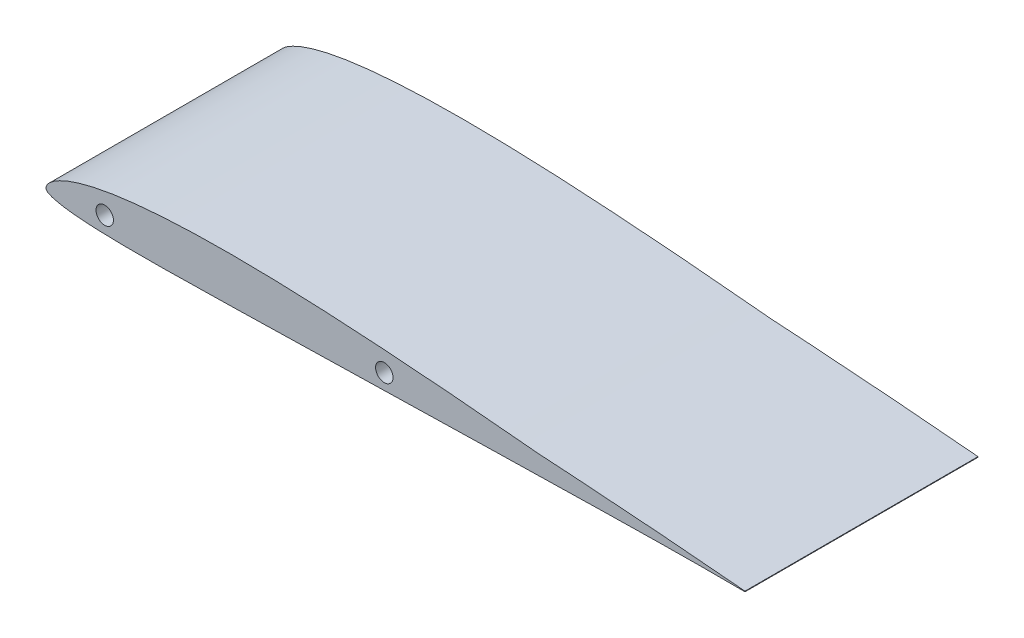
from build123d import *

# Parameters (mm, degrees)
BOSS_EXTRUDE1_DEPTH = 12.7
SKETCH3_R           = 0.9525
CUT_EXTRUDE1_DEPTH  = 26.4000001


with BuildPart() as part:
    # Sketch2 → Boss-Extrude1 (new body, symmetric)
    with BuildSketch(Plane.XY):
        with BuildLine():
            Line((64.718169848, -2.499143417), (64.718169848, -2.563456217))
            add(Edge.make_bspline(
                [(64.718169848, -2.499143417), (64.57008636, -2.485647197), (64.120909862, -2.444709582), (63.33092074, -2.371899023), (62.340988393, -2.285370828), (61.302858292, -2.194006348), (60.255749726, -2.102061217), (59.20564087, -2.013761116), (58.154298765, -1.925517783), (57.102103695, -1.839326159), (56.049602468, -1.754055917), (54.997055842, -1.670644215), (53.944788878, -1.589446986), (52.892846219, -1.508577494), (51.841324845, -1.430244971), (50.790005293, -1.352784355), (49.739245225, -1.276796753), (48.688636524, -1.202920087), (47.638508452, -1.129434553), (46.588535299, -1.057980828), (45.538973846, -0.987918085), (44.489525544, -0.919015022), (43.518569776, -0.856341226), (42.76371797, -0.809534693), (42.292113415, -0.778415282), (42.025102923, -0.764814001), (41.759900322, -0.736388122), (41.202070401, -0.684614179), (40.352064753, -0.602008925), (39.458214557, -0.518614415), (38.659237572, -0.444523122), (37.943339835, -0.378547436), (37.046267968, -0.297124129), (35.998306453, -0.203164046), (34.928593526, -0.109310266), (33.861679664, -0.017438796), (32.855925072, 0.067572446), (31.866593503, 0.149614421), (31.004614735, 0.219417223), (30.293193682, 0.276018624), (29.510637716, 0.337620449), (28.603924699, 0.406949286), (27.54916619, 0.48546654), (26.495103884, 0.561602222), (25.090353833, 0.659252903), (23.685759277, 0.751291385), (22.281448375, 0.837223705), (21.228463131, 0.898255328), (19.824860498, 0.975033121), (18.421400918, 1.044436007), (17.018020949, 1.105700039), (15.965855347, 1.147620542), (14.913927824, 1.184599621), (13.86231012, 1.216897884), (12.811147492, 1.244135927), (11.760493176, 1.266133962), (10.710364611, 1.282102535), (9.660770547, 1.292262127), (8.611804321, 1.295567333), (7.563748545, 1.2918548), (6.516728957, 1.280563888), (5.470993065, 1.261320698), (4.426697539, 1.233075932), (3.384243741, 1.195262013), (2.344154999, 1.147118546), (1.30677499, 1.087405461), (0.272951002, 1.01553077), (-0.756620414, 0.929630454), (-1.780995367, 0.828802249), (-2.798496801, 0.71071689), (-3.807643769, 0.574000519), (-4.805483481, 0.415836094), (-5.789196027, 0.233022375), (-6.753228823, 0.021955146), (-7.688827407, -0.221784244), (-8.578803858, -0.500074337), (-9.390128632, -0.81024109), (-10.075256249, -1.135525802), (-10.597529728, -1.448279294), (-10.957831672, -1.722355697), (-11.191738015, -1.949535299), (-11.340509909, -2.137925591), (-11.430618932, -2.298135772), (-11.476263277, -2.435744728), (-11.486757749, -2.556943481), (-11.460570081, -2.67120322), (-11.385368171, -2.78094718), (-11.252723362, -2.878628732), (-11.060363948, -2.977989982), (-10.777566168, -3.085187835), (-10.357827972, -3.204452959), (-9.76381891, -3.326330683), (-9.001331339, -3.439940748), (-8.116566771, -3.534084158), (-7.163694507, -3.606537927), (-6.176610039, -3.660215446), (-5.170969518, -3.698306831), (-4.153573582, -3.724180705), (-3.127995371, -3.740661828), (-2.096446559, -3.749635345), (-1.060235457, -3.752445761), (-0.020474584, -3.749525578), (1.022277045, -3.741896418), (2.067312992, -3.730492352), (3.114426337, -3.715621838), (4.163393847, -3.698251135), (5.214518698, -3.678787057), (6.267806047, -3.657863163), (7.323370126, -3.635311381), (8.381208951, -3.612442836), (9.441526554, -3.58839108), (10.504158632, -3.563905056), (11.92468281, -3.530891983), (13.347254295, -3.497196209), (14.771533214, -3.463588408), (15.841306634, -3.438409492), (16.911989828, -3.413034467), (17.983720411, -3.387888031), (19.056638023, -3.362504757), (20.130171202, -3.337425871), (21.203624946, -3.312336311), (22.276341611, -3.287377164), (23.348379195, -3.262811402), (24.419769067, -3.237871165), (25.490460003, -3.213616847), (26.560356365, -3.189302594), (27.629547828, -3.165394729), (28.698274525, -3.141302604), (29.602999191, -3.121201632), (30.657839619, -3.097853241), (31.698496831, -3.074385325), (32.881556151, -3.048178049), (33.911248665, -3.025327622), (34.944439624, -3.002098161), (35.988356279, -2.978974483), (36.922745567, -2.958275767), (37.740802843, -2.940242749), (38.431888121, -2.925199346), (39.226828943, -2.907764909), (40.139859265, -2.888092993), (40.983543149, -2.869810874), (41.55545359, -2.857761964), (41.832816963, -2.851718705), (42.068512365, -2.847220389), (42.546962239, -2.836679811), (43.325221031, -2.820460579), (44.348128788, -2.799096504), (45.404564547, -2.777351387), (46.460445741, -2.756095746), (47.516040759, -2.734807335), (48.571770091, -2.714116178), (49.627668411, -2.693328458), (50.683826195, -2.673277267), (51.740126636, -2.653577236), (52.796721419, -2.635838614), (54.205844553, -2.613436359), (55.615446657, -2.59433613), (57.025184273, -2.578294433), (58.082920356, -2.568677707), (59.140702632, -2.560641626), (60.198743058, -2.555318446), (61.256274736, -2.552644269), (62.307053135, -2.552213775), (63.310478787, -2.556353053), (64.112102133, -2.560000457), (64.56782734, -2.562598973), (64.718169848, -2.563456217)],
                knots=[0, 0, 0, 0, 0.002900997, 0.008799492, 0.015477521, 0.022287594, 0.029131106, 0.035984573, 0.042846882, 0.049714298, 0.05658103, 0.063447841, 0.070313229, 0.077171168, 0.084031174, 0.090884627, 0.097737396, 0.104584409, 0.111431996, 0.118274877, 0.125116136, 0.131953905, 0.138793041, 0.144098463, 0.146708547, 0.148014316, 0.149313147, 0.151910856, 0.158944662, 0.165973894, 0.169425198, 0.174599098, 0.179999827, 0.186998484, 0.195126222, 0.200949457, 0.207890371, 0.214817866, 0.220316978, 0.224762114, 0.228741132, 0.235631413, 0.242503169, 0.249375779, 0.256249105, 0.269975124, 0.276837254, 0.283697593, 0.290552693, 0.304261607, 0.311111523, 0.317957829, 0.324804965, 0.331646618, 0.338483878, 0.345319338, 0.352148661, 0.358973535, 0.365797142, 0.372613328, 0.379420455, 0.386224885, 0.393018255, 0.399801226, 0.406575621, 0.413331117, 0.420072962, 0.426793048, 0.433486562, 0.440153627, 0.446776036, 0.453352888, 0.45986197, 0.466293612, 0.472602109, 0.478718386, 0.484476601, 0.489534097, 0.493495639, 0.496331131, 0.498346313, 0.499841011, 0.500999224, 0.501914653, 0.502649229, 0.503345398, 0.504157805, 0.50518516, 0.50652574, 0.508375842, 0.511073875, 0.515031357, 0.520196697, 0.526108615, 0.532386125, 0.538838474, 0.545393385, 0.552018993, 0.558693317, 0.565404176, 0.572144526, 0.578909155, 0.585689295, 0.592488493, 0.599298368, 0.606119897, 0.612956027, 0.619808707, 0.626672964, 0.633554162, 0.640451345, 0.647364459, 0.654290996, 0.668172424, 0.675125782, 0.68208558, 0.689048858, 0.69602005, 0.703000172, 0.70998671, 0.716969769, 0.723948347, 0.730920449, 0.737890086, 0.744856199, 0.751814362, 0.758768528, 0.765720713, 0.772669892, 0.776423534, 0.786305074, 0.792977667, 0.799509992, 0.806398719, 0.813139713, 0.819881191, 0.82463258, 0.829103409, 0.833367055, 0.84014514, 0.846920231, 0.849830697, 0.851305256, 0.85233271, 0.85442981, 0.86064179, 0.867519383, 0.874390494, 0.8812566, 0.888123181, 0.894988723, 0.901857217, 0.908727131, 0.915597457, 0.922468599, 0.929343575, 0.943092095, 0.949971604, 0.956848493, 0.963728748, 0.970608901, 0.977490477, 0.984360632, 0.991108924, 0.997066858, 1, 1, 1, 1], degree=3))
        make_face()
    extrude(amount=BOSS_EXTRUDE1_DEPTH, both=True)

    # Sketch3 → Cut-Extrude1 (cut, through all)
    with BuildSketch(Plane.XY.offset(12.7)):
        with Locations((-5.08, -1.905)):
            Circle(SKETCH3_R)
        with Locations((25.4, -1.524)):
            Circle(SKETCH3_R)
    extrude(amount=-CUT_EXTRUDE1_DEPTH, mode=Mode.SUBTRACT)


solid = part.part
